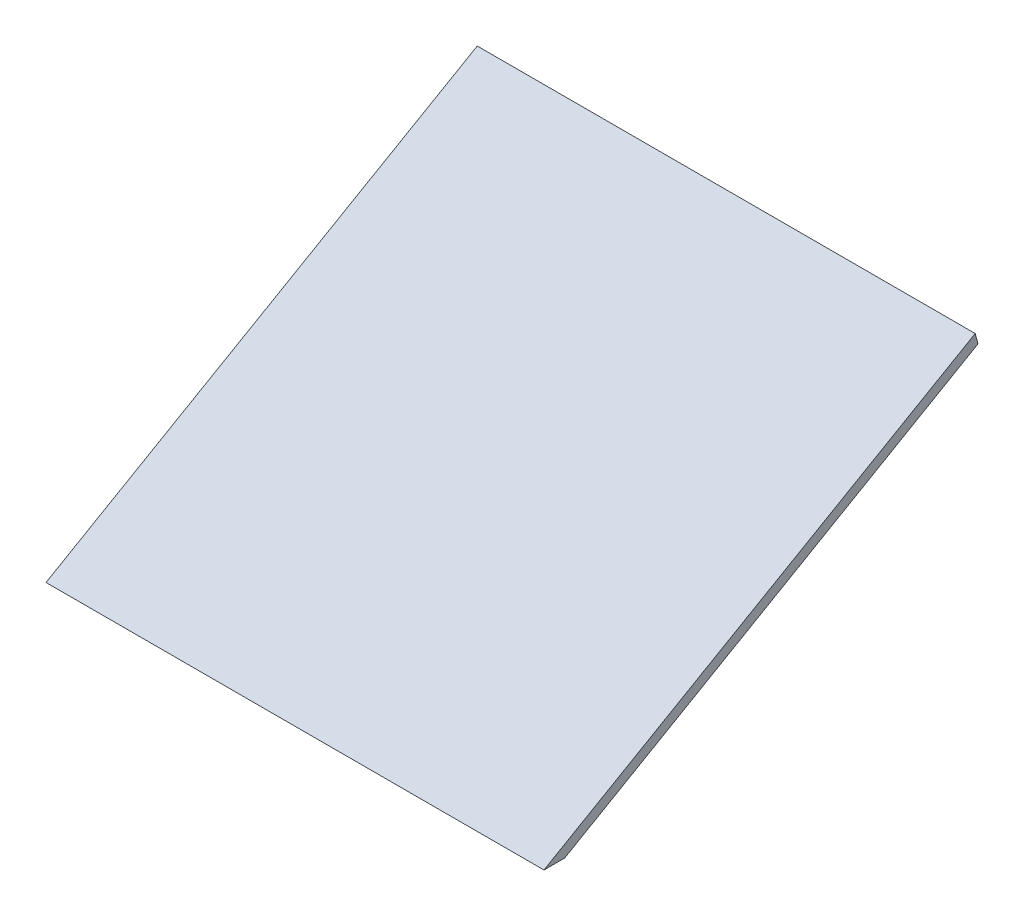
from build123d import *

# Parameters (mm, degrees)
BOSS_EXTRUDE1_DEPTH = 609.6


with BuildPart() as part:
    # Sketch1 → Boss-Extrude1 (new body)
    with BuildSketch(Plane(origin=(0, 0, 0), x_dir=(0, 0, -1), z_dir=(1, 0, 0))):
        Polygon((0, 0), (25.4, 0), (531.332040891, 292.1), (527.929086147, 304.8), align=None)
    extrude(amount=BOSS_EXTRUDE1_DEPTH)


solid = part.part
